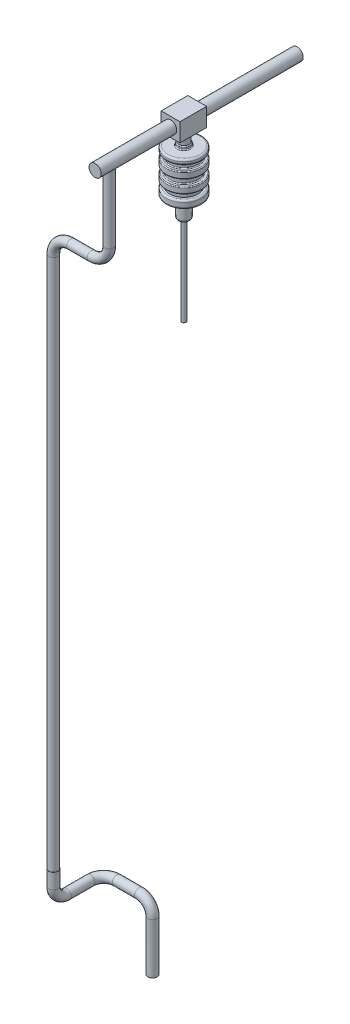
from build123d import *

# Parameters (mm, degrees)
CROQUIS2_R                   = 11.349269333
SALIENTE_EXTRUIR1_DEPTH      = 30
SALIENTE_EXTRUIR2_DEPTH      = 30
SALIENTE_EXTRUIR2_DEPTH_BACK = 30
CROQUIS3_W                   = 42.197298712
CROQUIS3_H                   = 41.423400297
CROQUIS3_R                   = 13.7
SALIENTE_EXTRUIR3_DEPTH      = 200
SALIENTE_EXTRUIR3_DEPTH_BACK = 200
CROQUIS4_R                   = 13.7
CROQUIS5_R                   = 5
SALIENTE_EXTRUIR4_DEPTH      = 200
CROQUIS6_R                   = 10.0766095
BARRER2_PROFILE_R            = 10.5
CROQUIS7_R                   = 13.7
SALIENTE_EXTRUIR5_DEPTH      = 55


with BuildPart() as part:
    # Croquis1 → Revolución1 (revolve)
    with BuildSketch(Plane.XY):
        with BuildLine():
            Line((0, 0), (8.349269333, 0))
            ThreePointArc((8.349269333, 0), (11.884803239, 1.464466094), (13.349269333, 5))
            Line((13.349269333, 5), (13.349269333, 40.611540427))
            ThreePointArc((13.349269333, 40.611540427), (14.813735427, 44.147074333), (18.349269333, 45.611540427))
            Line((18.349269333, 45.611540427), (36, 45.611540427))
            ThreePointArc((36, 45.611540427), (38.828427125, 46.783113303), (40, 49.611540427))
            Line((40, 49.611540427), (40, 59.428463305))
            ThreePointArc((40, 59.428463305), (38.828427125, 62.25689043), (36, 63.428463305))
            Line((36, 63.428463305), (31.601610056, 63.428463305))
            Line((31.601610056, 63.428463305), (31.601610056, 73))
            ThreePointArc((31.601610056, 73), (32.187396494, 74.414213562), (33.601610056, 75))
            Line((33.601610056, 75), (38, 75))
            ThreePointArc((38, 75), (39.414213562, 75.585786438), (40, 77))
            Line((40, 77), (40, 87.65170098))
            ThreePointArc((40, 87.65170098), (39.414213562, 89.065914542), (38, 89.65170098))
            Line((38, 89.65170098), (33.601610056, 89.65170098))
            ThreePointArc((33.601610056, 89.65170098), (32.187396494, 90.237487418), (31.601610056, 91.65170098))
            Line((31.601610056, 91.65170098), (31.601610056, 102.11969418))
            ThreePointArc((31.601610056, 102.11969418), (32.187396494, 103.533907742), (33.601610056, 104.11969418))
            Line((33.601610056, 104.11969418), (38, 104.11969418))
            ThreePointArc((38, 104.11969418), (39.414213562, 104.705480618), (40, 106.11969418))
            Line((40, 106.11969418), (40, 117.491936955))
            ThreePointArc((40, 117.491936955), (39.414213562, 118.906150517), (38, 119.491936955))
            Line((38, 119.491936955), (33.601610056, 119.491936955))
            ThreePointArc((33.601610056, 119.491936955), (32.187396494, 120.077723393), (31.601610056, 121.491936955))
            Line((31.601610056, 121.491936955), (31.601610056, 128.93954592))
            ThreePointArc((31.601610056, 128.93954592), (32.187396494, 130.353759482), (33.601610056, 130.93954592))
            Line((33.601610056, 130.93954592), (36, 130.93954592))
            ThreePointArc((36, 130.93954592), (38.828427125, 132.111118795), (40, 134.93954592))
            Line((40, 134.93954592), (40, 138.846276558))
            ThreePointArc((40, 138.846276558), (38.828427125, 141.674703682), (36, 142.846276558))
            Line((36, 142.846276558), (15.349269333, 142.846276558))
            ThreePointArc((15.349269333, 142.846276558), (13.935055771, 143.432062995), (13.349269333, 144.846276558))
            Line((13.349269333, 144.846276558), (13.349269333, 148))
            ThreePointArc((13.349269333, 148), (12.763482895, 149.414213562), (11.349269333, 150))
            Line((11.349269333, 150), (0, 150))
            Line((0, 150), (0, 0))
        make_face()
    revolve(axis=Axis((0, 0, 0), (0, 1, 0)))

    # Croquis2 → Saliente-Extruir1 (add)
    with BuildSketch(Plane(origin=(0, 150, 0), x_dir=(1, 0, 0), z_dir=(0, 1, 0))):
        Circle(CROQUIS2_R)
    extrude(amount=SALIENTE_EXTRUIR1_DEPTH)

    # Croquis3 → Saliente-Extruir2 (add, two sides: drawn at the far end of the back side and taken through both)
    with BuildSketch(Plane.XY.offset(-SALIENTE_EXTRUIR2_DEPTH_BACK)):
        with Locations((0, 193.5216321)):
            Rectangle(CROQUIS3_W, CROQUIS3_H)
        with Locations((0, 193.5216321)):
            Circle(CROQUIS3_R, mode=Mode.SUBTRACT)
    extrude(amount=SALIENTE_EXTRUIR2_DEPTH + SALIENTE_EXTRUIR2_DEPTH_BACK)

    # Croquis4 → Saliente-Extruir3 (add, two sides: drawn at the far end of the back side and taken through both)
    with BuildSketch(Plane.XY.offset(-SALIENTE_EXTRUIR3_DEPTH_BACK)):
        with Locations((0, 193.5216321)):
            Circle(CROQUIS4_R)
    extrude(amount=SALIENTE_EXTRUIR3_DEPTH + SALIENTE_EXTRUIR3_DEPTH_BACK)

    # Croquis5 → Saliente-Extruir4 (add)
    with BuildSketch(Plane.XZ):
        Circle(CROQUIS5_R)
    extrude(amount=SALIENTE_EXTRUIR4_DEPTH)

    # Barrer1: sweep along a curve in space
    with BuildLine() as barrer1_path:
        Line((0, 190, 167.900993318), (0, 31.527550207, 167.900993318))
        ThreePointArc((0, 31.527550207, 167.900993318), (-11.715728753, 3.24327896, 167.900993318), (-40, -8.472449793, 167.900993318))
        Line((-40, -8.472449793, 167.900993318), (-86.16617494, -8.472449793, 167.900993318))
        ThreePointArc((-86.16617494, -8.472449793, 167.900993318), (-114.450446187, -20.188178545, 167.900993318), (-126.16617494, -48.472449793, 167.900993318))
        Line((-126.16617494, -48.472449793, 167.900993318), (-126.16617494, -1247.142849291, 167.900993318))
    # Croquis6 → Barrer1 (sweep)
    with BuildSketch(Plane(origin=(0, 190, 0), x_dir=(1, 0, 0), z_dir=(0, 1, 0))):
        with Locations((0, -167.900993318)):
            Circle(CROQUIS6_R)
    sweep(path=barrer1_path.line)

    # Barrer2: sweep along a curve in space
    with BuildLine() as barrer2_path:
        Line((-126.16617494, -1247.142849291, 167.900993318), (-126.16617494, -1281.241236432, 167.900993318))
        ThreePointArc((-126.16617494, -1281.241236432, 167.900993318), (-126.16617494, -1302.454439868, 159.114196753), (-126.16617494, -1311.241236432, 137.900993318))
        Line((-126.16617494, -1311.241236432, 137.900993318), (-126.16617494, -1311.241236432, 84.533679537))
        ThreePointArc((-126.16617494, -1311.241236432, 84.533679537), (-117.379378375, -1311.241236432, 63.320476101), (-96.16617494, -1311.241236432, 54.533679537))
        Line((-96.16617494, -1311.241236432, 54.533679537), (-46.16617494, -1311.241236432, 54.533679537))
        ThreePointArc((-46.16617494, -1311.241236432, 54.533679537), (-24.952971504, -1320.028032997, 54.533679537), (-16.16617494, -1341.241236432, 54.533679537))
        Line((-16.16617494, -1341.241236432, 54.533679537), (-16.16617494, -1454.826081359, 54.533679537))
    # Barrer2 profile (on start of the path) → Barrer2 (sweep)
    with BuildSketch(Plane(origin=(-126.16617494, -1247.142849291, 167.900993318), x_dir=(-1, 0, 0), z_dir=(0, -1, 0))):
        Circle(BARRER2_PROFILE_R)
    sweep(path=barrer2_path.line)

    # Croquis7 → Saliente-Extruir5 (add)
    with BuildSketch(Plane(origin=(0, 0, -200), x_dir=(-1, 0, 0), z_dir=(0, 0, -1))):
        with Locations((0, 193.5216321)):
            Circle(CROQUIS7_R)
    extrude(amount=SALIENTE_EXTRUIR5_DEPTH)


solid = part.part
